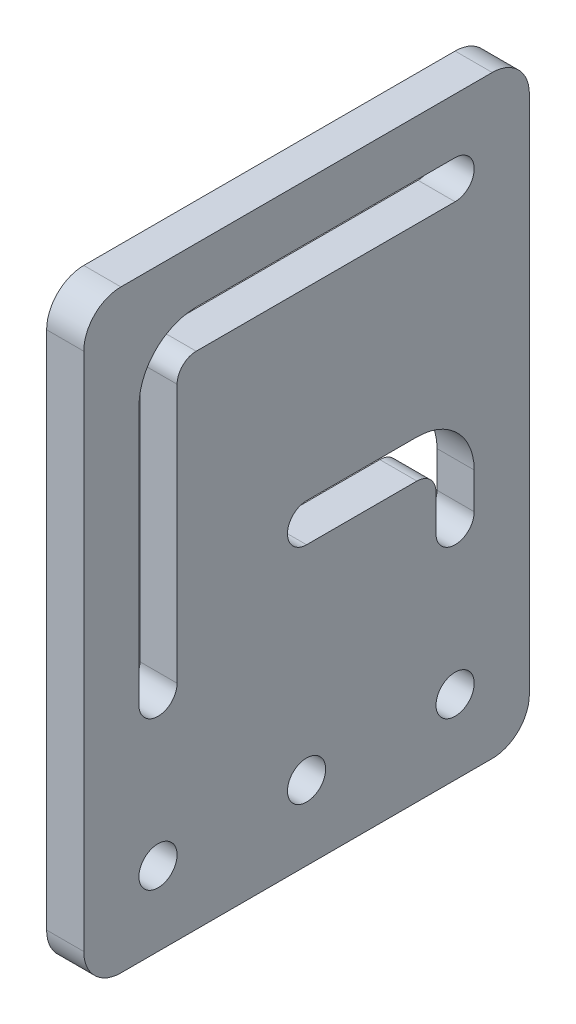
from build123d import *

# Parameters (mm, degrees)
SKETCH1_W      = 76.2
SKETCH1_H      = 101.6
SKETCH1_R      = 3.2639
EXTRUDE1_DEPTH = 6.35
FILLET2_R      = 3.2639
FILLET3_R      = 9.7917
FILLET4_R      = 6.35


with BuildPart() as part:
    # Sketch1 → Extrude1 (new body)
    with BuildSketch(Plane(origin=(0, 0, 0), x_dir=(0, 0, -1), z_dir=(1, 0, 0))):
        with Locations((38.1, 50.8)):
            Rectangle(SKETCH1_W, SKETCH1_H)
        with Locations((12.7, 12.7)):
            Circle(SKETCH1_R, mode=Mode.SUBTRACT)
        with Locations((38.1, 12.7)):
            Circle(SKETCH1_R, mode=Mode.SUBTRACT)
        with Locations((63.5, 12.7)):
            Circle(SKETCH1_R, mode=Mode.SUBTRACT)
        with BuildLine():
            Line((38.1, 47.5361), (60.2361, 47.5361))
            Line((60.2361, 47.5361), (60.2361, 38.1))
            ThreePointArc((60.2361, 38.1), (63.5, 34.8361), (66.7639, 38.1))
            Line((66.7639, 38.1), (66.7639, 54.0639))
            Line((66.7639, 54.0639), (38.1, 54.0639))
            ThreePointArc((38.1, 54.0639), (34.8361, 50.8), (38.1, 47.5361))
        make_face(mode=Mode.SUBTRACT)
        with BuildLine():
            Line((15.9639, 38.1), (15.9639, 85.6361))
            Line((15.9639, 85.6361), (63.5, 85.6361))
            ThreePointArc((63.5, 85.6361), (66.7639, 88.9), (63.5, 92.1639))
            Line((63.5, 92.1639), (9.4361, 92.1639))
            Line((9.4361, 92.1639), (9.4361, 38.1))
            ThreePointArc((9.4361, 38.1), (12.7, 34.8361), (15.9639, 38.1))
        make_face(mode=Mode.SUBTRACT)
    extrude(amount=EXTRUDE1_DEPTH)

    # Fillet2
    fillet2_edges = [part.edges().sort_by_distance(p)[0] for p in [
        (3.175, 47.5361, -60.2361),
        (3.175, 85.6361, -15.9639),
    ]]
    fillet(fillet2_edges, radius=FILLET2_R)

    # Fillet3
    fillet3_edges = [part.edges().sort_by_distance(p)[0] for p in [
        (3.175, 54.0639, -66.7639),
        (3.175, 92.1639, -9.4361),
    ]]
    fillet(fillet3_edges, radius=FILLET3_R)

    # Fillet4
    fillet4_edges = [part.edges().sort_by_distance(p)[0] for p in [
        (3.175, 101.6, 0),
        (3.175, 101.6, -76.2),
        (3.175, 0, -76.2),
        (3.175, 0, 0),
    ]]
    fillet(fillet4_edges, radius=FILLET4_R)


solid = part.part
